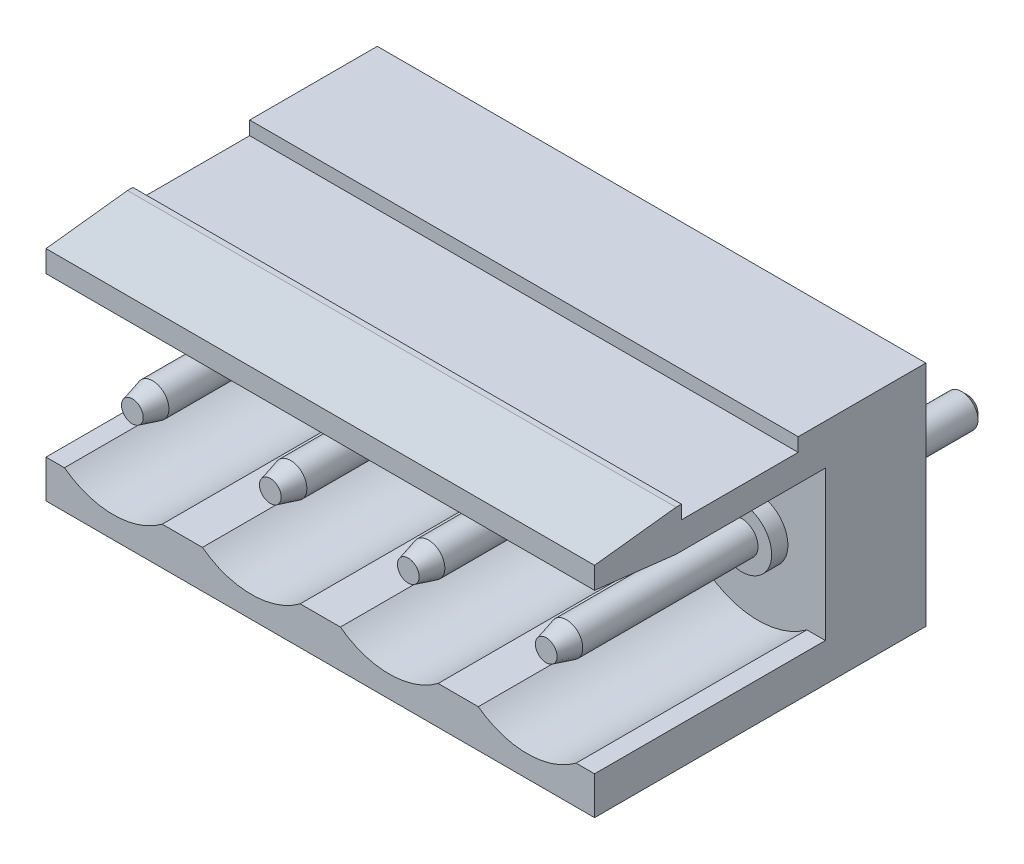
from build123d import *

# Parameters (mm, degrees)
ESQUISSE1_W             = 20.2
ESQUISSE1_H             = 8.4
BOSS_EXTRU_1_DEPTH      = 12.2
ENL_V_MAT_EXTRU_1_DEPTH = 8.5
ESQUISSE3_W             = 4.3
ESQUISSE3_H             = 0.5
ENL_V_MAT_EXTRU_2_DEPTH = 21.2
ESQUISSE4_R             = 0.6
BOSS_EXTRU_2_DEPTH      = 4
BOSS_EXTRU_2_DEPTH_BACK = 11.5
CHANFREIN1_SIZE         = 0.2
CHANFREIN1_SIZE2        = 0.746410162
CHANFREIN1_PART_2_SIZE  = 0.2
CHANFREIN1_PART_2_SIZE2 = 0.746410162
CHANFREIN1_PART_3_SIZE  = 0.2
CHANFREIN1_PART_3_SIZE2 = 0.746410162
CHANFREIN1_PART_4_SIZE  = 0.2
CHANFREIN1_PART_4_SIZE2 = 0.746410162
CHANFREIN2_SIZE         = 0.2
ESQUISSE5_R             = 1.1
BOSS_EXTRU_3_DEPTH      = 0.6


with BuildPart() as part:
    # Esquisse1 → Boss.-Extru.1 (new body)
    with BuildSketch(Plane.XY):
        with Locations((10.1, 4.2)):
            Rectangle(ESQUISSE1_W, ESQUISSE1_H)
    extrude(amount=BOSS_EXTRU_1_DEPTH)

    # Esquisse2 → Enlèv. mat.-Extru.1 (cut)
    with BuildSketch(Plane.XY.offset(12.2)):
        with BuildLine():
            Line((0, 1.4), (0, 6.9))
            Line((0, 6.9), (20.2, 6.9))
            Line((20.2, 6.9), (20.2, 1.4))
            Line((20.2, 1.4), (19.52, 1.4))
            ThreePointArc((19.52, 1.4), (17.72, 0.8), (15.92, 1.4))
            Line((15.92, 1.4), (14.44, 1.4))
            ThreePointArc((14.44, 1.4), (12.64, 0.8), (10.84, 1.4))
            Line((10.84, 1.4), (9.36, 1.4))
            ThreePointArc((9.36, 1.4), (7.56, 0.8), (5.76, 1.4))
            Line((5.76, 1.4), (4.28, 1.4))
            ThreePointArc((4.28, 1.4), (2.48, 0.8), (0.68, 1.4))
            Line((0.68, 1.4), (0, 1.4))
        make_face()
    extrude(amount=-ENL_V_MAT_EXTRU_1_DEPTH, mode=Mode.SUBTRACT)

    # Esquisse3 → Enlèv. mat.-Extru.2 (cut, through all)
    with BuildSketch(Plane.ZY):
        with Locations((6.85, 8.15)):
            Rectangle(ESQUISSE3_W, ESQUISSE3_H)
        Polygon((12.2, 8.4), (9.2, 8.4), (12.2, 8.05), align=None)
        Polygon((12.2, 7.25), (12.2, 6.9), (9.2, 6.9), align=None)
    extrude(amount=-ENL_V_MAT_EXTRU_2_DEPTH, mode=Mode.SUBTRACT)

    # Esquisse4 → Boss.-Extru.2 (add, two sides)
    with BuildSketch(Plane(origin=(0, 0, 0), x_dir=(-1, 0, 0), z_dir=(0, 0, -1))) as boss_extru_2_sk:
        with Locations((-17.72, 3.75)):
            Circle(ESQUISSE4_R)
        with Locations((-12.64, 3.75)):
            Circle(ESQUISSE4_R)
        with Locations((-2.48, 3.75)):
            Circle(ESQUISSE4_R)
        with Locations((-7.56, 3.75)):
            Circle(ESQUISSE4_R)
    extrude(amount=BOSS_EXTRU_2_DEPTH)
    extrude(boss_extru_2_sk.sketch, amount=-BOSS_EXTRU_2_DEPTH_BACK)

    # Chanfrein1
    chanfrein1_edges = [part.edges().sort_by_distance(p)[0] for p in [
        (8.16, 3.75, 11.5),
    ]]
    chanfrein1_side = [part.faces().sort_by_distance(p)[0] for p in [
        (7.56, 3.75, 11.5),
    ]]
    chamfer(chanfrein1_edges, length=CHANFREIN1_SIZE, length2=CHANFREIN1_SIZE2, reference=chanfrein1_side[0])

    # Chanfrein1 part 2
    chanfrein1_part_2_edges = [part.edges().sort_by_distance(p)[0] for p in [
        (18.32, 3.75, 11.5),
    ]]
    chanfrein1_part_2_side = [part.faces().sort_by_distance(p)[0] for p in [
        (17.72, 3.75, 11.5),
    ]]
    chamfer(chanfrein1_part_2_edges, length=CHANFREIN1_PART_2_SIZE, length2=CHANFREIN1_PART_2_SIZE2, reference=chanfrein1_part_2_side[0])

    # Chanfrein1 part 3
    chanfrein1_part_3_edges = [part.edges().sort_by_distance(p)[0] for p in [
        (13.24, 3.75, 11.5),
    ]]
    chanfrein1_part_3_side = [part.faces().sort_by_distance(p)[0] for p in [
        (12.64, 3.75, 11.5),
    ]]
    chamfer(chanfrein1_part_3_edges, length=CHANFREIN1_PART_3_SIZE, length2=CHANFREIN1_PART_3_SIZE2, reference=chanfrein1_part_3_side[0])

    # Chanfrein1 part 4
    chanfrein1_part_4_edges = [part.edges().sort_by_distance(p)[0] for p in [
        (3.08, 3.75, 11.5),
    ]]
    chanfrein1_part_4_side = [part.faces().sort_by_distance(p)[0] for p in [
        (2.48, 3.75, 11.5),
    ]]
    chamfer(chanfrein1_part_4_edges, length=CHANFREIN1_PART_4_SIZE, length2=CHANFREIN1_PART_4_SIZE2, reference=chanfrein1_part_4_side[0])

    # Chanfrein2
    chanfrein2_edges = [part.edges().sort_by_distance(p)[0] for p in [
        (8.16, 3.75, -4),
        (18.32, 3.75, -4),
        (13.24, 3.75, -4),
        (3.08, 3.75, -4),
    ]]
    chamfer(chanfrein2_edges, length=CHANFREIN2_SIZE)

    # Esquisse5 → Boss.-Extru.3 (add)
    with BuildSketch(Plane.XY.offset(3.7)):
        with Locations((12.64, 3.75)):
            Circle(ESQUISSE5_R)
        with Locations((17.72, 3.75)):
            Circle(ESQUISSE5_R)
        with Locations((7.56, 3.75)):
            Circle(ESQUISSE5_R)
        with Locations((2.48, 3.75)):
            Circle(ESQUISSE5_R)
    extrude(amount=BOSS_EXTRU_3_DEPTH)


solid = part.part
